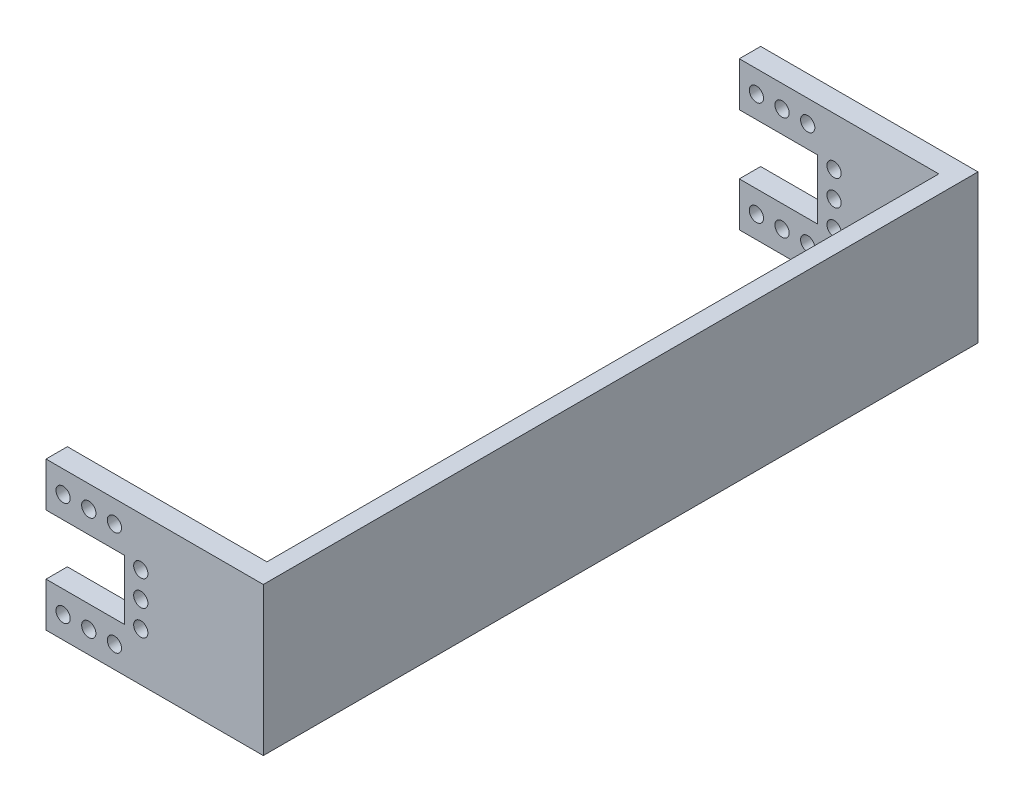
from build123d import *

# Parameters (mm, degrees)
SKETCH_3_R      = 1
EXTRUDE_2_DEPTH = 3
SKETCH_5_W      = 100.3
SKETCH_5_H      = 20.8
EXTRUDE_4_DEPTH = 2.5


with BuildPart() as part:
    # 스케치3 → 보스-돌출2 (new body)
    with BuildSketch(Plane(origin=(0, 0, -47.45), x_dir=(-1, 0, 0), z_dir=(0, 0, -1))):
        with BuildLine():
            ThreePointArc((-20.85, 0), (-17.803910524, 7.353910524), (-10.45, 10.4))
            Line((-10.45, 10.4), (-20.85, 10.4))
            Line((-20.85, 10.4), (-32.45, 10.4))
            Line((-32.45, 10.4), (-32.45, 0))
            Line((-32.45, 0), (-20.85, 0))
        make_face()
        with BuildLine():
            Line((-20.85, -10.4), (-10.45, -10.4))
            ThreePointArc((-10.45, -10.4), (-17.803910524, -7.353910524), (-20.85, 0))
            Line((-20.85, 0), (-32.45, 0))
            Line((-32.45, 0), (-32.45, -10.4))
            Line((-32.45, -10.4), (-20.85, -10.4))
        make_face()
        with BuildLine():
            Line((-16.75, 0), (-15.45, 0))
            Line((-15.45, 0), (-15.45, 4.2))
            Line((-15.45, 4.2), (-4.45, 4.2))
            Line((-4.45, 4.2), (-4.45, 8.494704233))
            ThreePointArc((-4.45, 8.494704233), (-7.302375818, 9.912237992), (-10.45, 10.4))
            ThreePointArc((-10.45, 10.4), (-17.803910524, 7.353910524), (-20.85, 0))
            Line((-20.85, 0), (-18.75, 0))
            ThreePointArc((-18.75, 0), (-17.75, 1), (-16.75, 0))
        make_face()
        with Locations((-17.75, 3.6)):
            Circle(SKETCH_3_R, mode=Mode.SUBTRACT)
        with Locations((-14.05, 7.3)):
            Circle(SKETCH_3_R, mode=Mode.SUBTRACT)
        with Locations((-10.45, 7.3)):
            Circle(SKETCH_3_R, mode=Mode.SUBTRACT)
        with Locations((-6.85, 7.3)):
            Circle(SKETCH_3_R, mode=Mode.SUBTRACT)
        with BuildLine():
            Line((-15.45, -4.2), (-15.45, 0))
            Line((-15.45, 0), (-16.75, 0))
            ThreePointArc((-16.75, 0), (-17.75, -1), (-18.75, 0))
            Line((-18.75, 0), (-20.85, 0))
            ThreePointArc((-20.85, 0), (-17.803910524, -7.353910524), (-10.45, -10.4))
            ThreePointArc((-10.45, -10.4), (-7.302375818, -9.912237992), (-4.45, -8.494704233))
            Line((-4.45, -8.494704233), (-4.45, -4.2))
            Line((-4.45, -4.2), (-15.45, -4.2))
        make_face()
        with Locations((-17.75, -3.6)):
            Circle(SKETCH_3_R, mode=Mode.SUBTRACT)
        with Locations((-14.05, -7.3)):
            Circle(SKETCH_3_R, mode=Mode.SUBTRACT)
        with Locations((-10.45, -7.3)):
            Circle(SKETCH_3_R, mode=Mode.SUBTRACT)
        with Locations((-6.85, -7.3)):
            Circle(SKETCH_3_R, mode=Mode.SUBTRACT)
        with BuildLine():
            ThreePointArc((-10.45, 10.4), (-7.302375818, 9.912237992), (-4.45, 8.494704233))
            Line((-4.45, 8.494704233), (-4.45, 10.4))
            Line((-4.45, 10.4), (-10.45, 10.4))
        make_face()
        with BuildLine():
            Line((-4.45, -10.4), (-4.45, -8.494704233))
            ThreePointArc((-4.45, -8.494704233), (-7.302375818, -9.912237992), (-10.45, -10.4))
            Line((-10.45, -10.4), (-4.45, -10.4))
        make_face()
    extrude(amount=EXTRUDE_2_DEPTH)


with BuildPart() as body_2:
    # 대칭 복사7: mirrored copy
    add(part.part.mirror(Plane(origin=(0, 0, -0.3), x_dir=(1, 0, 0), z_dir=(0, 0, -1))))


with BuildPart() as part_1:
    add(part.part)

    add(body_2.part)  # 보스-돌출4 merges body 2
    # 스케치5 → 보스-돌출4 (add)
    with BuildSketch(Plane(origin=(32.45, 0, 0), x_dir=(0, 0, -1), z_dir=(1, 0, 0))):
        with Locations((0.3, 0)):
            Rectangle(SKETCH_5_W, SKETCH_5_H)
    extrude(amount=EXTRUDE_4_DEPTH)


solid = part_1.part
